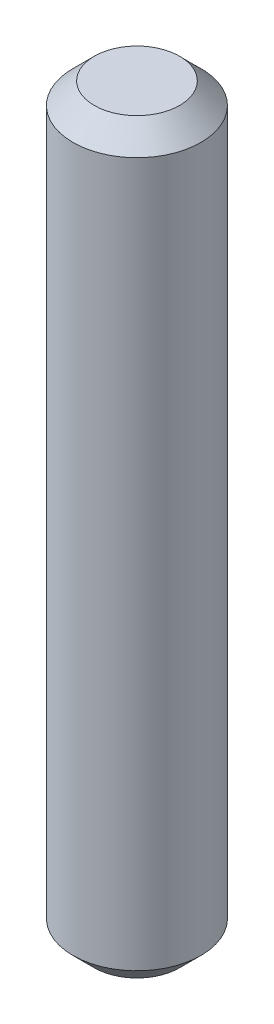
from build123d import *

# Parameters (mm, degrees)
SKETCH1_R           = 6
BOSS_EXTRUDE1_DEPTH = 70
CHAMFER1_SIZE       = 2


with BuildPart() as part:
    # Sketch1 → Boss-Extrude1 (new body)
    with BuildSketch(Plane(origin=(0, 0, 0), x_dir=(1, 0, 0), z_dir=(0, 1, 0))):
        Circle(SKETCH1_R)
    extrude(amount=BOSS_EXTRUDE1_DEPTH)

    # Chamfer1
    chamfer1_edges = [part.edges().sort_by_distance(p)[0] for p in [
        (-6, 0, 0),
        (-6, 70, 0),
    ]]
    chamfer(chamfer1_edges, length=CHAMFER1_SIZE)


solid = part.part
